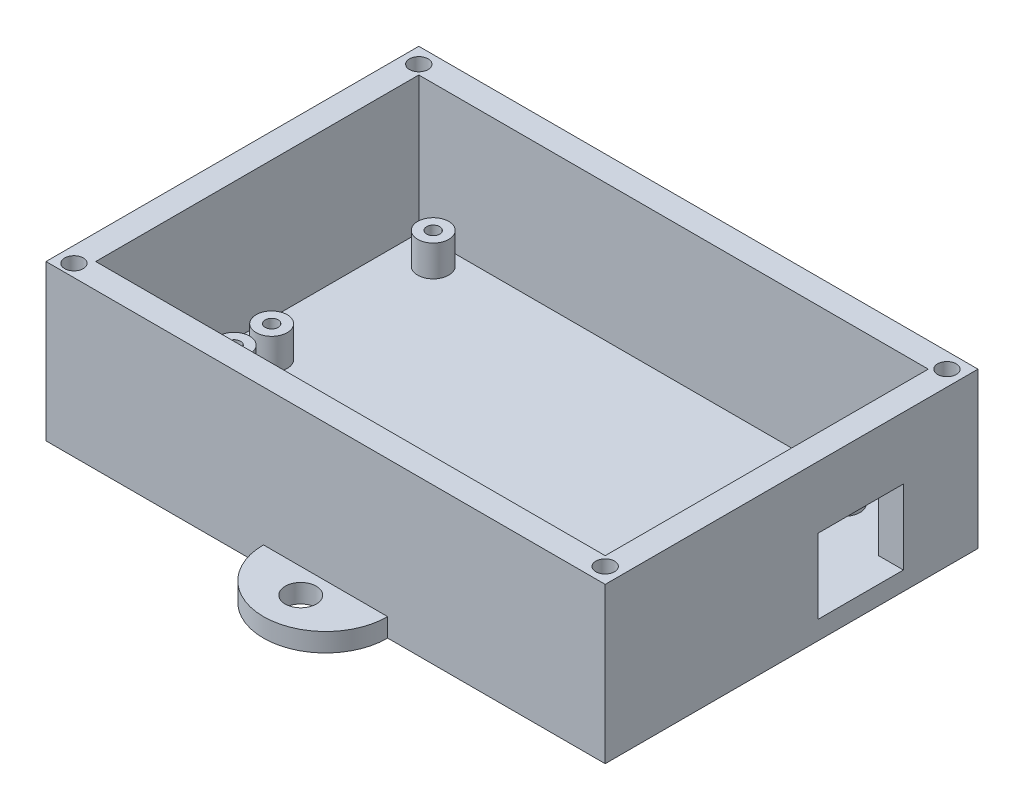
from build123d import *

# Parameters (mm, degrees)
SKETCH1_R           = 2.5
BOSS_EXTRUDE1_DEPTH = 3
SKETCH2_R           = 2.5
BOSS_EXTRUDE2_DEPTH = 5
SKETCH4_R           = 1.05
CUT_EXTRUDE2_DEPTH  = 4.5
SKETCH6_W           = 90
SKETCH6_H           = 60
SKETCH6_W_2         = 82
SKETCH6_H_2         = 52
BOSS_EXTRUDE3_DEPTH = 22
SKETCH7_W           = 13.75
SKETCH7_H           = 12
CUT_EXTRUDE3_DEPTH  = 20
SKETCH8_R           = 1.5
CUT_EXTRUDE4_DEPTH  = 10
SKETCH10_W          = 6.5
SKETCH10_H          = 5.005531991
CUT_EXTRUDE5_DEPTH  = 10


with BuildPart() as part:
    # Sketch1 → Boss-Extrude1 (new body)
    with BuildSketch(Plane(origin=(0, 0, 0), x_dir=(1, 0, 0), z_dir=(0, 1, 0))):
        with BuildLine():
            Line((-45, 30), (-10, 30))
            ThreePointArc((-10, 30), (0, 40), (10, 30))
            Line((10, 30), (45, 30))
            Line((45, 30), (45, -30))
            Line((45, -30), (10, -30))
            ThreePointArc((10, -30), (0, -40), (-10, -30))
            Line((-10, -30), (-45, -30))
            Line((-45, -30), (-45, 30))
        make_face()
        with Locations((0, 34)):
            Circle(SKETCH1_R, mode=Mode.SUBTRACT)
        with Locations((0, -34)):
            Circle(SKETCH1_R, mode=Mode.SUBTRACT)
    extrude(amount=BOSS_EXTRUDE1_DEPTH)

    # Sketch2 → Boss-Extrude2 (add)
    with BuildSketch(Plane(origin=(0, 3, 0), x_dir=(1, 0, 0), z_dir=(0, 1, 0))):
        with Locations((-35.17920076, 22.499548704)):
            Circle(SKETCH2_R)
        with Locations((31, 22.499548704)):
            Circle(SKETCH2_R)
        with Locations((31, -3.500451296)):
            Circle(SKETCH2_R)
        with Locations((-35.17920076, -3.500451296)):
            Circle(SKETCH2_R)
        with Locations((-35.220554781, -9.500308782)):
            Circle(SKETCH2_R)
        with Locations((31, -9.500308782)):
            Circle(SKETCH2_R)
        with Locations((-35.310155161, -22.5)):
            Circle(SKETCH2_R)
        with Locations((31, -22.5)):
            Circle(SKETCH2_R)
    extrude(amount=BOSS_EXTRUDE2_DEPTH)

    # Sketch4 → Cut-Extrude2 (cut)
    with BuildSketch(Plane(origin=(0, 8, 0), x_dir=(1, 0, 0), z_dir=(0, 1, 0))):
        with Locations((-35.17920076, 22.499548704)):
            Circle(SKETCH4_R)
        with Locations((31, 22.499548704)):
            Circle(SKETCH4_R)
        with Locations((31, -3.500451296)):
            Circle(SKETCH4_R)
        with Locations((31, -9.500308782)):
            Circle(SKETCH4_R)
        with Locations((-35.17920076, -3.500451296)):
            Circle(SKETCH4_R)
        with Locations((-35.220554781, -9.500308782)):
            Circle(SKETCH4_R)
        with Locations((-35.310155161, -22.5)):
            Circle(SKETCH4_R)
        with Locations((31, -22.5)):
            Circle(SKETCH4_R)
    extrude(amount=-CUT_EXTRUDE2_DEPTH, mode=Mode.SUBTRACT)

    # Sketch6 → Boss-Extrude3 (add)
    with BuildSketch(Plane(origin=(0, 3, 0), x_dir=(1, 0, 0), z_dir=(0, 1, 0))):
        Rectangle(SKETCH6_W, SKETCH6_H)
        Rectangle(SKETCH6_W_2, SKETCH6_H_2, mode=Mode.SUBTRACT)
    extrude(amount=BOSS_EXTRUDE3_DEPTH)

    # Sketch7 → Cut-Extrude3 (cut)
    with BuildSketch(Plane.ZY.offset(-41)):
        with Locations((-11.125, 9)):
            Rectangle(SKETCH7_W, SKETCH7_H)
    extrude(amount=-CUT_EXTRUDE3_DEPTH, mode=Mode.SUBTRACT)

    # Sketch8 → Cut-Extrude4 (cut)
    with BuildSketch(Plane(origin=(0, 25, 0), x_dir=(1, 0, 0), z_dir=(0, 1, 0))):
        with Locations((-42.5, 27.5)):
            Circle(SKETCH8_R)
        with Locations((42.5, 27.5)):
            Circle(SKETCH8_R)
        with Locations((-42.5, -28)):
            Circle(SKETCH8_R)
        with Locations((42.5, -27.5)):
            Circle(SKETCH8_R)
    extrude(amount=-CUT_EXTRUDE4_DEPTH, mode=Mode.SUBTRACT)

    # Sketch10 → Cut-Extrude5 (cut)
    with BuildSketch(Plane(origin=(-41, 0, 0), x_dir=(0, 0, -1), z_dir=(1, 0, 0))):
        with Locations((-16.050308782, 5.502765995)):
            Rectangle(SKETCH10_W, SKETCH10_H)
    extrude(amount=-CUT_EXTRUDE5_DEPTH, mode=Mode.SUBTRACT)


solid = part.part
